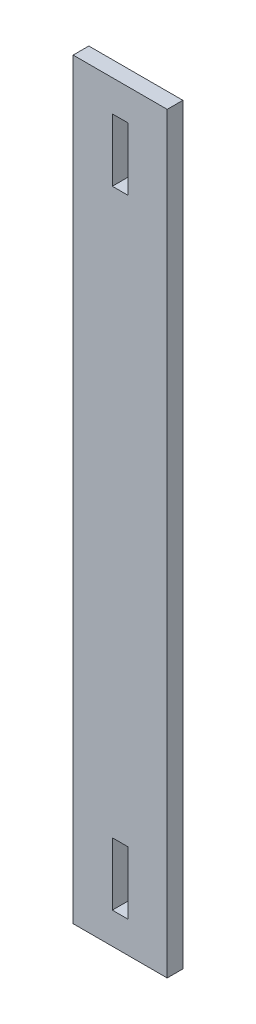
from build123d import *

# Parameters (mm, degrees)
SKETCH1_W           = 38.1
SKETCH1_H           = 304.8
BOSS_EXTRUDE1_DEPTH = 6.35
SKETCH2_W           = 6.35
SKETCH2_H           = 25.4
CUT_EXTRUDE1_DEPTH  = 7.35


with BuildPart() as part:
    # Sketch1 → Boss-Extrude1 (new body)
    with BuildSketch(Plane.XY):
        Rectangle(SKETCH1_W, SKETCH1_H)
    extrude(amount=BOSS_EXTRUDE1_DEPTH)

    # Sketch2 → Cut-Extrude1 (cut, through all)
    with BuildSketch(Plane.XY.offset(6.35)):
        with Locations((0, 127)):
            Rectangle(SKETCH2_W, SKETCH2_H)
    cut_extrude1 = extrude(amount=-CUT_EXTRUDE1_DEPTH, mode=Mode.SUBTRACT)

    # Mirror1: Cut-Extrude1 across plane
    add(cut_extrude1.mirror(Plane.ZX), mode=Mode.SUBTRACT)


solid = part.part
